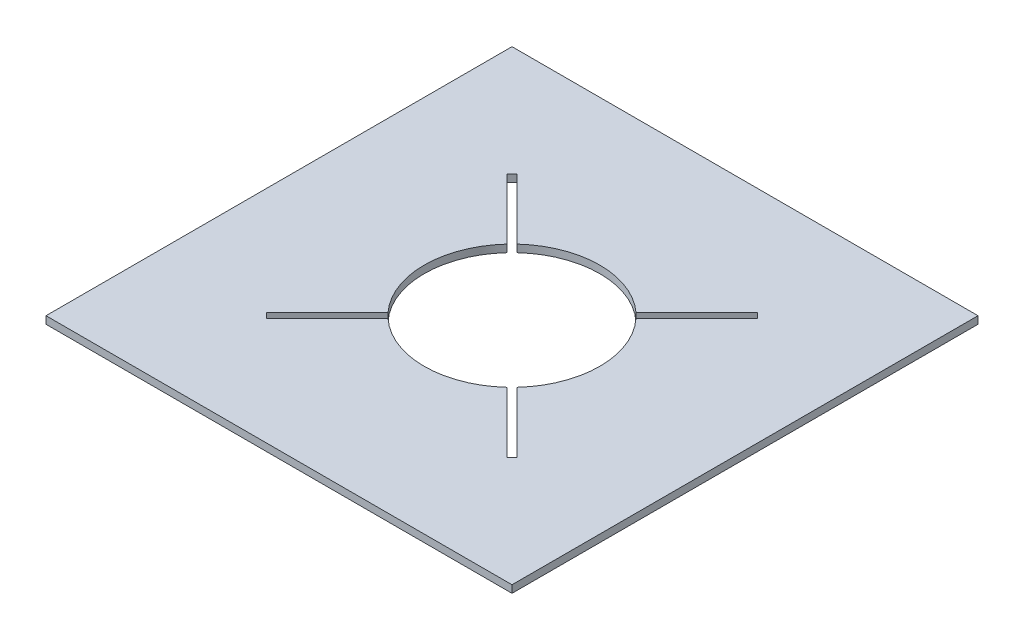
from build123d import *

# Parameters (mm, degrees)
SKETCH4_W           = 413.09178157
SKETCH4_H           = 413.09178157
BOSS_EXTRUDE3_DEPTH = 6.604
SKETCH6_R           = 77.79258
CUT_EXTRUDE1_DEPTH  = 6.604
CUT_EXTRUDE2_DEPTH  = 6.604
CUT_EXTRUDE3_DEPTH  = 6.604


with BuildPart() as part:
    # Sketch4 → Boss-Extrude3 (new body)
    with BuildSketch(Plane(origin=(0, 0, 0), x_dir=(1, 0, 0), z_dir=(0, 1, 0))):
        Rectangle(SKETCH4_W, SKETCH4_H)
    extrude(amount=BOSS_EXTRUDE3_DEPTH)

    # Sketch6 → Cut-Extrude1 (cut)
    with BuildSketch(Plane(origin=(0, 6.604, 0), x_dir=(1, 0, 0), z_dir=(0, 1, 0))):
        Circle(SKETCH6_R)
    extrude(amount=-CUT_EXTRUDE1_DEPTH, mode=Mode.SUBTRACT)

    # Sketch8 → Cut-Extrude2 (cut)
    with BuildSketch(Plane(origin=(0, 6.604, 0), x_dir=(1, 0, 0), z_dir=(0, 1, 0))):
        Polygon((-111.193531291, -106.595640157), (106.595640157, 111.193531291), (111.193531291, 106.595640157), (-106.595640157, -111.193531291), align=None)
    extrude(amount=-CUT_EXTRUDE2_DEPTH, mode=Mode.SUBTRACT)

    # Sketch9 → Cut-Extrude3 (cut)
    with BuildSketch(Plane(origin=(0, 6.604, 0), x_dir=(1, 0, 0), z_dir=(0, 1, 0))):
        Polygon((111.202511547, -106.586659901), (-106.586659901, 111.202511547), (-111.202511547, 106.586659901), (106.586659901, -111.202511547), align=None)
    extrude(amount=-CUT_EXTRUDE3_DEPTH, mode=Mode.SUBTRACT)


solid = part.part
